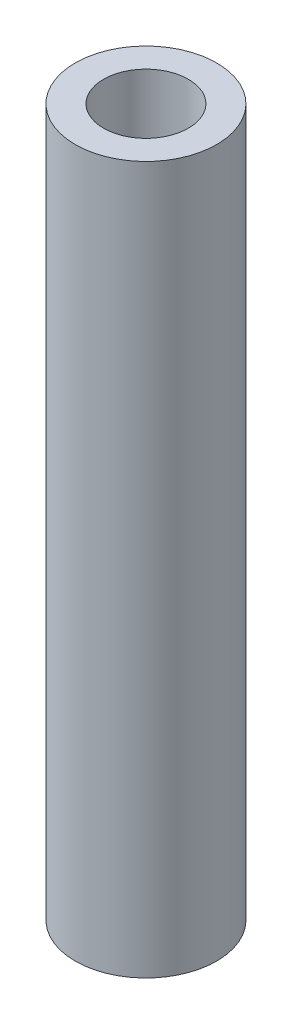
from build123d import *

# Parameters (mm, degrees)
SKETCH1_R           = 2.5
SKETCH1_R_2         = 1.5
BOSS_EXTRUDE1_DEPTH = 25


with BuildPart() as part:
    # Sketch1 → Boss-Extrude1 (new body)
    with BuildSketch(Plane(origin=(0, 0, 0), x_dir=(1, 0, 0), z_dir=(0, 1, 0))):
        Circle(SKETCH1_R)
        Circle(SKETCH1_R_2, mode=Mode.SUBTRACT)
    extrude(amount=BOSS_EXTRUDE1_DEPTH)


solid = part.part
